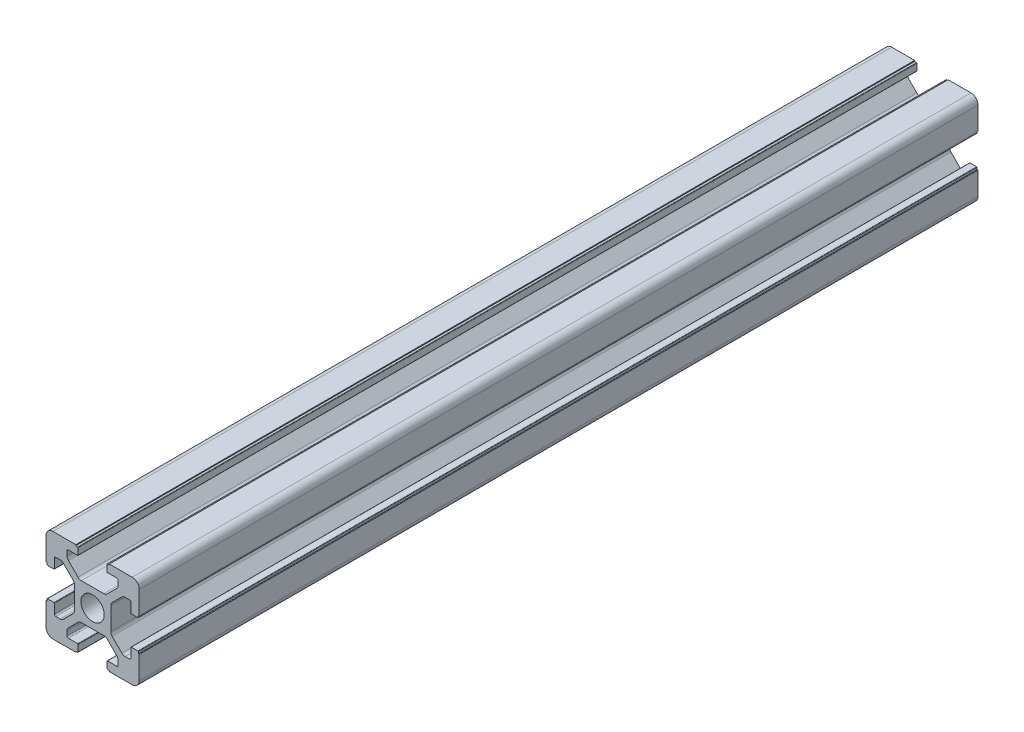
from build123d import *

# Parameters (mm, degrees)
SKETCH_1_R      = 2.5
EXTRUDE_1_DEPTH = 180
FILLET_1_R      = 1.5


with BuildPart() as part:
    # 草图1 → 凸台-拉伸1 (new body)
    with BuildSketch(Plane.XY):
        with BuildLine():
            Line((20, 13.6), (20, 20))
            Line((20, 20), (13.6, 20))
            Line((13.6, 20), (13.6, 19.8))
            Line((13.6, 19.8), (13.2, 19.8))
            ThreePointArc((13.2, 19.8), (13.129289322, 19.770710678), (13.1, 19.7))
            Line((13.1, 19.7), (13.1, 18.3))
            ThreePointArc((13.1, 18.3), (13.129289322, 18.229289322), (13.2, 18.2))
            Line((13.2, 18.2), (15.2, 18.2))
            ThreePointArc((15.2, 18.2), (15.412132034, 18.112132034), (15.5, 17.9))
            Line((15.5, 17.9), (15.5, 16.974873734))
            ThreePointArc((15.5, 16.974873734), (15.423879533, 16.592190302), (15.207106781, 16.267766953))
            Line((15.207106781, 16.267766953), (13.132233047, 14.192893219))
            ThreePointArc((13.132233047, 14.192893219), (12.807809698, 13.976120467), (12.425126266, 13.9))
            Line((12.425126266, 13.9), (7.574873734, 13.9))
            ThreePointArc((7.574873734, 13.9), (7.192190302, 13.976120467), (6.867766953, 14.192893219))
            Line((6.867766953, 14.192893219), (4.792893219, 16.267766953))
            ThreePointArc((4.792893219, 16.267766953), (4.576120467, 16.592190302), (4.5, 16.974873734))
            Line((4.5, 16.974873734), (4.5, 17.9))
            ThreePointArc((4.5, 17.9), (4.587867966, 18.112132034), (4.8, 18.2))
            Line((4.8, 18.2), (6.8, 18.2))
            ThreePointArc((6.8, 18.2), (6.870710678, 18.229289322), (6.9, 18.3))
            Line((6.9, 18.3), (6.9, 19.7))
            ThreePointArc((6.9, 19.7), (6.870710678, 19.770710678), (6.8, 19.8))
            Line((6.8, 19.8), (6.4, 19.8))
            Line((6.4, 19.8), (6.4, 20))
            Line((6.4, 20), (0, 20))
            Line((0, 20), (0, 13.6))
            Line((0, 13.6), (0.2, 13.6))
            Line((0.2, 13.6), (0.2, 13.2))
            ThreePointArc((0.2, 13.2), (0.229289322, 13.129289322), (0.3, 13.1))
            Line((0.3, 13.1), (1.7, 13.1))
            ThreePointArc((1.7, 13.1), (1.770710678, 13.129289322), (1.8, 13.2))
            Line((1.8, 13.2), (1.8, 15.2))
            ThreePointArc((1.8, 15.2), (1.887867966, 15.412132034), (2.1, 15.5))
            Line((2.1, 15.5), (3.025126266, 15.5))
            ThreePointArc((3.025126266, 15.5), (3.407809698, 15.423879533), (3.732233047, 15.207106781))
            Line((3.732233047, 15.207106781), (5.807106781, 13.132233047))
            ThreePointArc((5.807106781, 13.132233047), (6.023879533, 12.807809698), (6.1, 12.425126266))
            Line((6.1, 12.425126266), (6.1, 7.574873734))
            ThreePointArc((6.1, 7.574873734), (6.023879533, 7.192190302), (5.807106781, 6.867766953))
            Line((5.807106781, 6.867766953), (3.732233047, 4.792893219))
            ThreePointArc((3.732233047, 4.792893219), (3.407809698, 4.576120467), (3.025126266, 4.5))
            Line((3.025126266, 4.5), (2.1, 4.5))
            ThreePointArc((2.1, 4.5), (1.887867966, 4.587867966), (1.8, 4.8))
            Line((1.8, 4.8), (1.8, 6.8))
            ThreePointArc((1.8, 6.8), (1.770710678, 6.870710678), (1.7, 6.9))
            Line((1.7, 6.9), (0.3, 6.9))
            ThreePointArc((0.3, 6.9), (0.229289322, 6.870710678), (0.2, 6.8))
            Line((0.2, 6.8), (0.2, 6.4))
            Line((0.2, 6.4), (0, 6.4))
            Line((0, 6.4), (0, 0))
            Line((0, 0), (6.4, 0))
            Line((6.4, 0), (6.4, 0.2))
            Line((6.4, 0.2), (6.8, 0.2))
            ThreePointArc((6.8, 0.2), (6.870710678, 0.229289322), (6.9, 0.3))
            Line((6.9, 0.3), (6.9, 1.7))
            ThreePointArc((6.9, 1.7), (6.870710678, 1.770710678), (6.8, 1.8))
            Line((6.8, 1.8), (4.8, 1.8))
            ThreePointArc((4.8, 1.8), (4.587867966, 1.887867966), (4.5, 2.1))
            Line((4.5, 2.1), (4.5, 3.025126266))
            ThreePointArc((4.5, 3.025126266), (4.576120467, 3.407809698), (4.792893219, 3.732233047))
            Line((4.792893219, 3.732233047), (6.867766953, 5.807106781))
            ThreePointArc((6.867766953, 5.807106781), (7.192190302, 6.023879533), (7.574873734, 6.1))
            Line((7.574873734, 6.1), (12.425126266, 6.1))
            ThreePointArc((12.425126266, 6.1), (12.807809698, 6.023879533), (13.132233047, 5.807106781))
            Line((13.132233047, 5.807106781), (15.207106781, 3.732233047))
            ThreePointArc((15.207106781, 3.732233047), (15.423879533, 3.407809698), (15.5, 3.025126266))
            Line((15.5, 3.025126266), (15.5, 2.1))
            ThreePointArc((15.5, 2.1), (15.412132034, 1.887867966), (15.2, 1.8))
            Line((15.2, 1.8), (13.2, 1.8))
            ThreePointArc((13.2, 1.8), (13.129289322, 1.770710678), (13.1, 1.7))
            Line((13.1, 1.7), (13.1, 0.3))
            ThreePointArc((13.1, 0.3), (13.129289322, 0.229289322), (13.2, 0.2))
            Line((13.2, 0.2), (13.6, 0.2))
            Line((13.6, 0.2), (13.6, 0))
            Line((13.6, 0), (20, 0))
            Line((20, 0), (20, 6.4))
            Line((20, 6.4), (19.8, 6.4))
            Line((19.8, 6.4), (19.8, 6.8))
            ThreePointArc((19.8, 6.8), (19.770710678, 6.870710678), (19.7, 6.9))
            Line((19.7, 6.9), (18.3, 6.9))
            ThreePointArc((18.3, 6.9), (18.229289322, 6.870710678), (18.2, 6.8))
            Line((18.2, 6.8), (18.2, 4.8))
            ThreePointArc((18.2, 4.8), (18.112132034, 4.587867966), (17.9, 4.5))
            Line((17.9, 4.5), (16.974873734, 4.5))
            ThreePointArc((16.974873734, 4.5), (16.592190302, 4.576120467), (16.267766953, 4.792893219))
            Line((16.267766953, 4.792893219), (14.192893219, 6.867766953))
            ThreePointArc((14.192893219, 6.867766953), (13.976120467, 7.192190302), (13.9, 7.574873734))
            Line((13.9, 7.574873734), (13.9, 12.425126266))
            ThreePointArc((13.9, 12.425126266), (13.976120467, 12.807809698), (14.192893219, 13.132233047))
            Line((14.192893219, 13.132233047), (16.267766953, 15.207106781))
            ThreePointArc((16.267766953, 15.207106781), (16.592190302, 15.423879533), (16.974873734, 15.5))
            Line((16.974873734, 15.5), (17.9, 15.5))
            ThreePointArc((17.9, 15.5), (18.112132034, 15.412132034), (18.2, 15.2))
            Line((18.2, 15.2), (18.2, 13.2))
            ThreePointArc((18.2, 13.2), (18.229289322, 13.129289322), (18.3, 13.1))
            Line((18.3, 13.1), (19.7, 13.1))
            ThreePointArc((19.7, 13.1), (19.770710678, 13.129289322), (19.8, 13.2))
            Line((19.8, 13.2), (19.8, 13.6))
            Line((19.8, 13.6), (20, 13.6))
        make_face()
        with Locations((10, 10)):
            Circle(SKETCH_1_R, mode=Mode.SUBTRACT)
    extrude(amount=EXTRUDE_1_DEPTH)

    # 圆角1
    fillet_1_edges = [part.edges().sort_by_distance(p)[0] for p in [
        (0, 0, 90),
        (0, 20, 90),
        (20, 20, 90),
        (20, 0, 90),
    ]]
    fillet(fillet_1_edges, radius=FILLET_1_R)


solid = part.part
